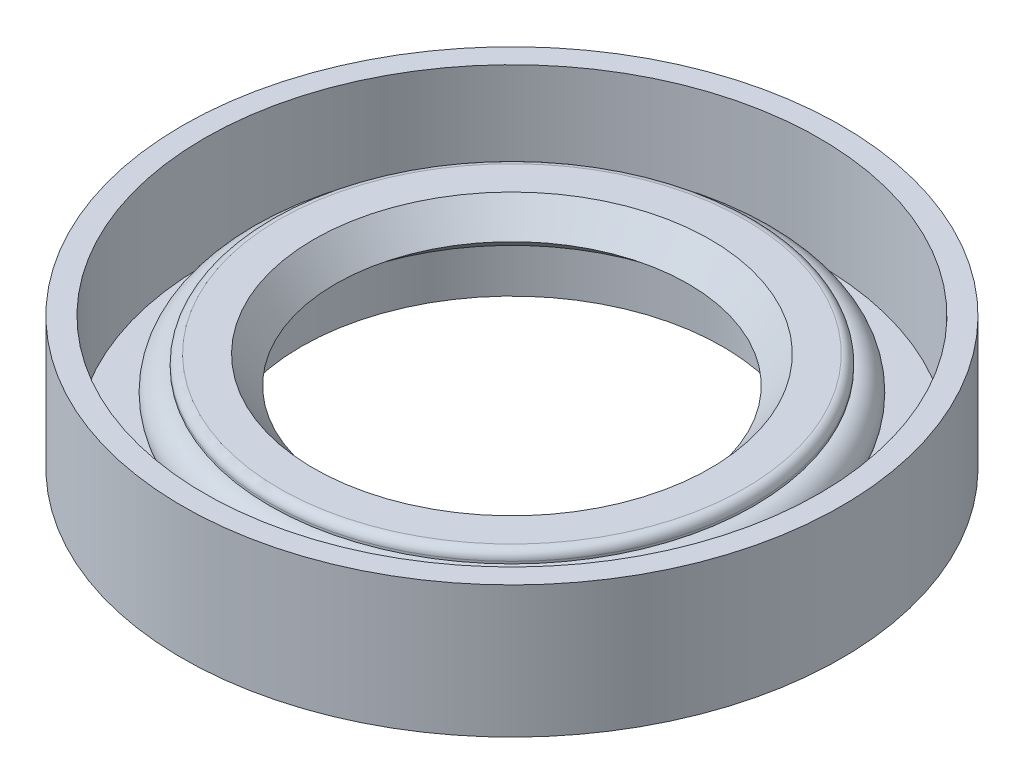
from build123d import *


with BuildPart() as part:
    # Sketch1 → Revolve1 (revolve)
    with BuildSketch(Plane.XY):
        with BuildLine():
            Line((9.585714286, -4.414285714), (15, -4.414285714))
            Line((15, -4.414285714), (15, 1.585714286))
            Line((15, 1.585714286), (14, 1.585714286))
            Line((14, 1.585714286), (14, -3.414285714))
            Line((14, -3.414285714), (11, -3.414285714))
            Line((11, -3.414285714), (11, -2.414285714))
            ThreePointArc((11, -2.414285714), (12, -1.414285714), (11, -0.414285714))
            Line((11, -0.414285714), (11, -0.314285714))
            ThreePointArc((11, -0.314285714), (10.882842712, -0.031443002), (10.6, 0.085714286))
            Line((10.6, 0.085714286), (9.024464786, 0.085714286))
            Line((9.024464786, 0.085714286), (8.024464786, -1.164285714))
            Line((8.024464786, -1.164285714), (9.585714286, -2.414285714))
            Line((9.585714286, -2.414285714), (9.585714286, -4.414285714))
        make_face()
    revolve(axis=Axis((0, 14.828571429, 0), (0, -1, 0)))


solid = part.part
